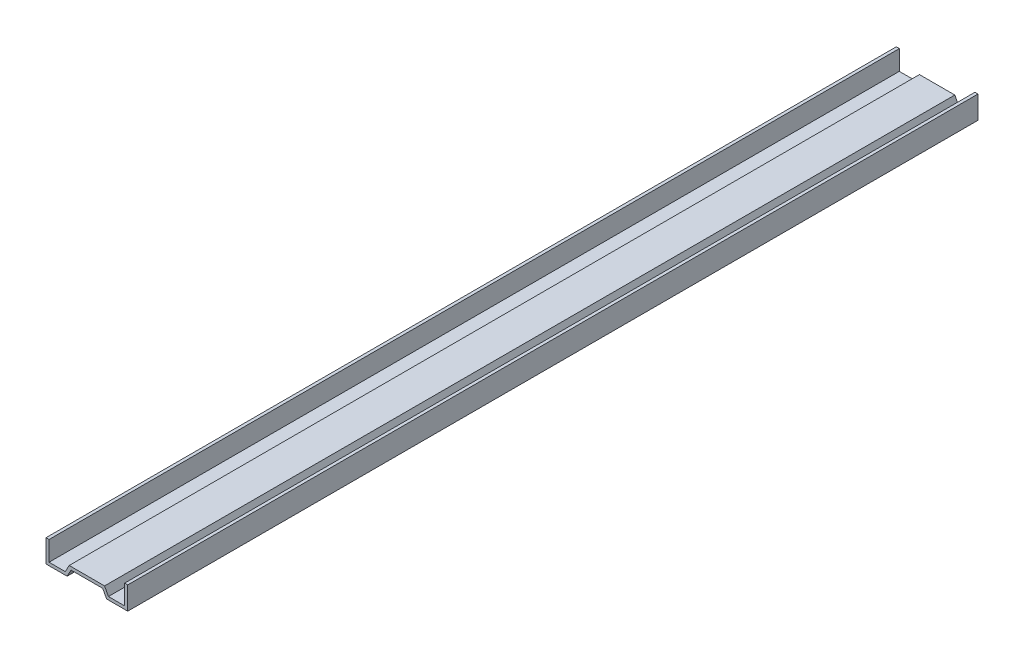
from build123d import *

# Parameters (mm, degrees)
BOSS_EXTRUDE1_DEPTH = 362
SCALE1_SCALE        = 0.25


with BuildPart() as part:
    # Sketch1 → Boss-Extrude1 (new body)
    with BuildSketch(Plane.XY.offset(362)):
        Polygon((-9.180453293, -3.095455134), (-16.1, -3.095455134), (-16.1, 5.304544866), (-17.4, 5.304544866), (-17.4, -4.395455134), (-8.4, -4.395455134), (-6.749887033, -1.3), (6.750112967, -1.3), (8.4, -4.395455134), (17.4, -4.395455134), (17.4, 5.304544866), (16.1, 5.304544866), (16.1, -3.095455134), (9.18022736, -3.095455134), (7.530340327, 0), (-7.530340327, 0), align=None)
    extrude(amount=-BOSS_EXTRUDE1_DEPTH)


with BuildPart() as part_1:
    # Scale1: scaled about (-7.7465e-05, -1.277039924, 181)
    add(part.part.scale(SCALE1_SCALE).moved(Location((-5.8099e-05, -0.957779943, 135.75))))


solid = part_1.part
